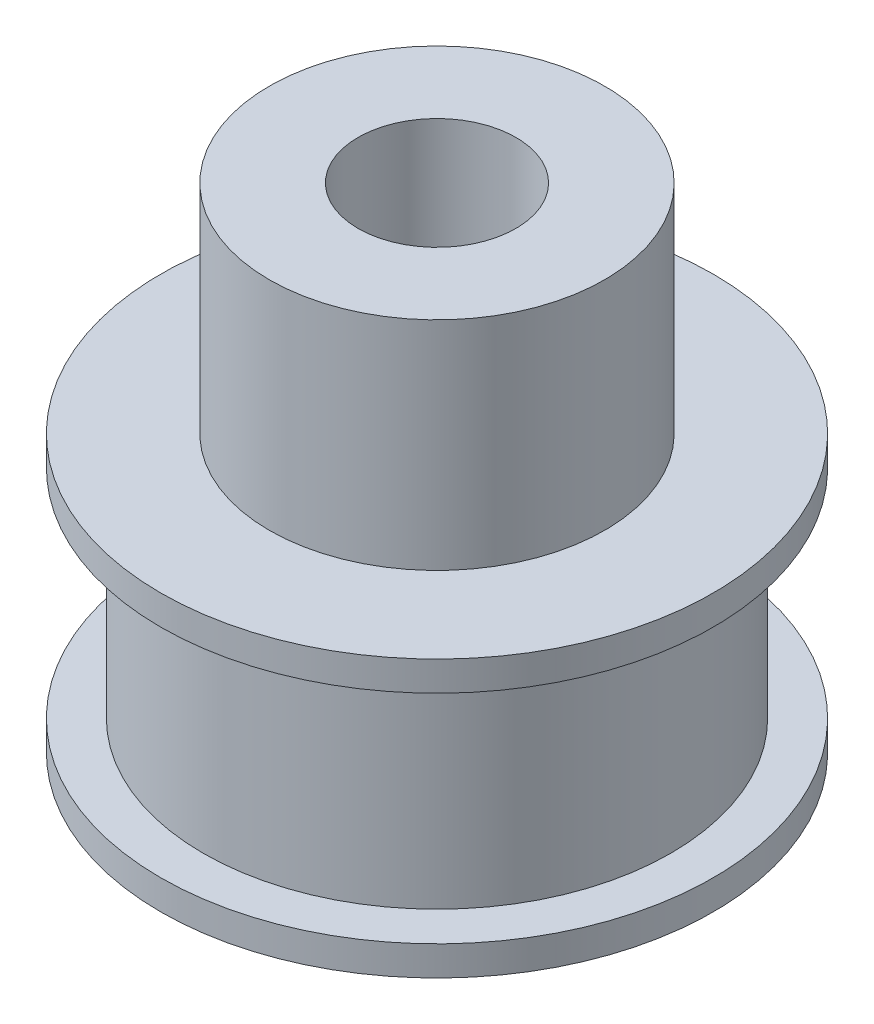
from build123d import *

# Parameters (mm, degrees)
SKETCH1_R           = 14
BOSS_EXTRUDE1_DEPTH = 1.5
SKETCH2_R           = 11.85
BOSS_EXTRUDE2_DEPTH = 11
SKETCH3_R           = 14
BOSS_EXTRUDE3_DEPTH = 1.5
SKETCH4_R           = 8.5
BOSS_EXTRUDE4_DEPTH = 11
SKETCH5_R           = 4
CUT_EXTRUDE1_DEPTH  = 26


with BuildPart() as part:
    # Sketch1 → Boss-Extrude1 (new body)
    with BuildSketch(Plane(origin=(0, 0, 0), x_dir=(1, 0, 0), z_dir=(0, 1, 0))):
        Circle(SKETCH1_R)
    extrude(amount=BOSS_EXTRUDE1_DEPTH)

    # Sketch2 → Boss-Extrude2 (add)
    with BuildSketch(Plane(origin=(0, 1.5, 0), x_dir=(1, 0, 0), z_dir=(0, 1, 0))):
        Circle(SKETCH2_R)
    extrude(amount=BOSS_EXTRUDE2_DEPTH)

    # Sketch3 → Boss-Extrude3 (add)
    with BuildSketch(Plane(origin=(0, 12.5, 0), x_dir=(1, 0, 0), z_dir=(0, 1, 0))):
        Circle(SKETCH3_R)
    extrude(amount=BOSS_EXTRUDE3_DEPTH)

    # Sketch4 → Boss-Extrude4 (add)
    with BuildSketch(Plane(origin=(0, 14, 0), x_dir=(1, 0, 0), z_dir=(0, 1, 0))):
        Circle(SKETCH4_R)
    extrude(amount=BOSS_EXTRUDE4_DEPTH)

    # Sketch5 → Cut-Extrude1 (cut, through all)
    with BuildSketch(Plane(origin=(0, 25, 0), x_dir=(1, 0, 0), z_dir=(0, 1, 0))):
        Circle(SKETCH5_R)
    extrude(amount=-CUT_EXTRUDE1_DEPTH, mode=Mode.SUBTRACT)


solid = part.part
